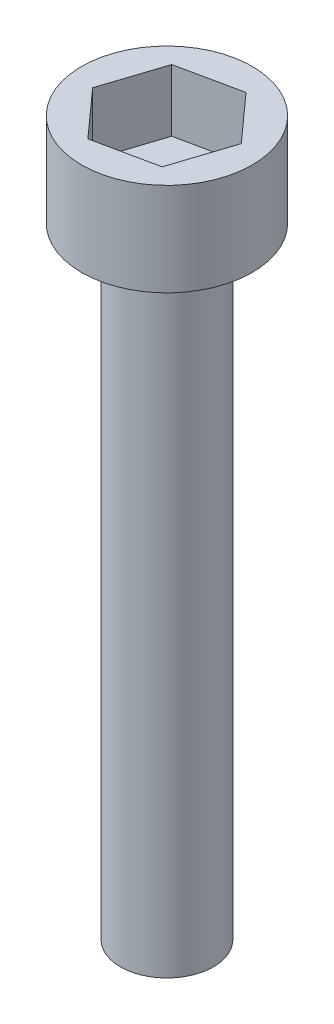
from build123d import *

# Parameters (mm, degrees)
SKETCH1_R           = 1.5
BOSS_EXTRUDE1_DEPTH = 20
SKETCH2_R           = 2.75
BOSS_EXTRUDE2_DEPTH = 3
CUT_EXTRUDE1_DEPTH  = 2


with BuildPart() as part:
    # Sketch1 → Boss-Extrude1 (new body)
    with BuildSketch(Plane(origin=(0, 0, 0), x_dir=(1, 0, 0), z_dir=(0, 1, 0))):
        Circle(SKETCH1_R)
    extrude(amount=BOSS_EXTRUDE1_DEPTH)

    # Sketch2 → Boss-Extrude2 (add)
    with BuildSketch(Plane(origin=(0, 20, 0), x_dir=(1, 0, 0), z_dir=(0, 1, 0))):
        Circle(SKETCH2_R)
    extrude(amount=BOSS_EXTRUDE2_DEPTH)

    # Sketch4 → Cut-Extrude1 (cut)
    with BuildSketch(Plane(origin=(0, 23, 0), x_dir=(1, 0, 0), z_dir=(0, 1, 0))):
        Polygon((1.977155875, 0.417358336), (0.627135016, 1.920946383), (-1.350020859, 1.503588046), (-1.977155875, -0.417358336), (-0.627135016, -1.920946383), (1.350020859, -1.503588046), align=None)
    extrude(amount=-CUT_EXTRUDE1_DEPTH, mode=Mode.SUBTRACT)


solid = part.part
